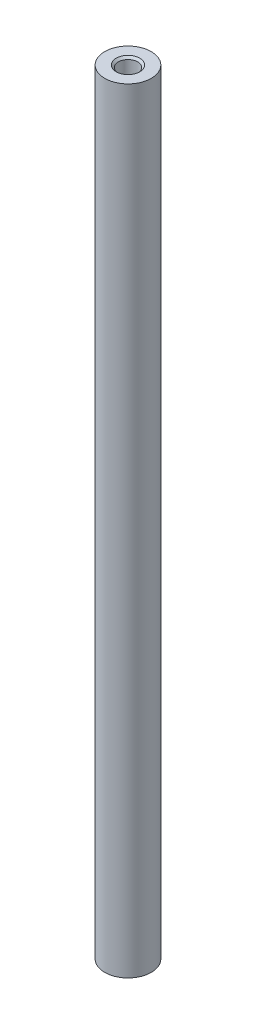
from build123d import *

# Parameters (mm, degrees)
SKETCH1_R           = 3
BOSS_EXTRUDE1_DEPTH = 100


with BuildPart() as part:
    # Sketch1 → Boss-Extrude1 (new body)
    with BuildSketch(Plane(origin=(0, 0, 0), x_dir=(1, 0, 0), z_dir=(0, 1, 0))):
        Circle(SKETCH1_R)
    extrude(amount=BOSS_EXTRUDE1_DEPTH)

    # Sketch3 → M3x0.5 Tapped Hole1 (revolve, cut)
    with BuildSketch(Plane(origin=(0, 0, 0), x_dir=(0, 0, -1), z_dir=(1, 0, 0))):
        Polygon((0, 0), (0, 5.751075774), (1.25, 5), (1.25, 0.275), (1.525, 0), align=None)
    m3x0_5_tapped_hole1 = revolve(axis=Axis((0, -6.35, 0), (0, 1, 0)), mode=Mode.SUBTRACT)

    # Mirror1: M3x0.5 Tapped Hole1 across plane
    add(m3x0_5_tapped_hole1.mirror(Plane.ZX.offset(50)), mode=Mode.SUBTRACT)


solid = part.part
